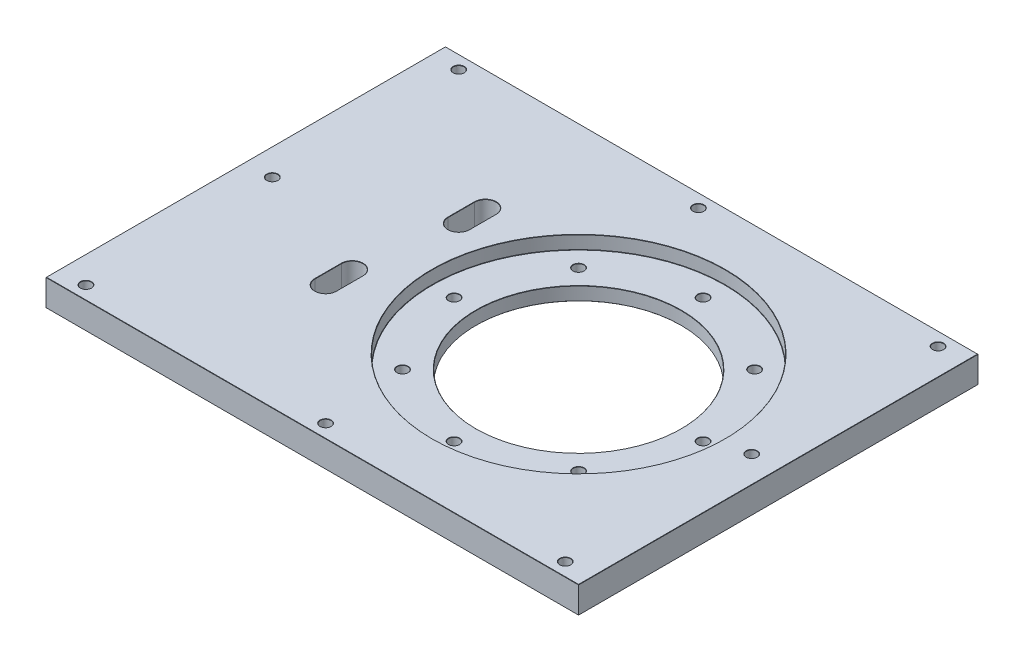
from build123d import *

# Parameters (mm, degrees)
SKETCH1_W           = 200
SKETCH1_H           = 150
SKETCH1_R           = 2
SKETCH1_R_2         = 55
BOSS_EXTRUDE1_DEPTH = 10
SKETCH1_3_R         = 55
SKETCH1_3_R_2       = 38.5
BOSS_EXTRUDE2_DEPTH = 5
SKETCH1_4_R         = 38.5
BOSS_EXTRUDE3_DEPTH = 9
SKETCH2_R           = 2
CUT_EXTRUDE1_DEPTH  = 146.859521458
SKETCH1_5_R         = 38.5
CUT_EXTRUDE2_DEPTH  = 147.116391962
CUT_EXTRUDE3_DEPTH  = 147.116391962
CHAMFER1_SIZE       = 0.1


with BuildPart() as part:
    # Sketch1 → Boss-Extrude1 (new body)
    with BuildSketch(Plane(origin=(0, 0, 0), x_dir=(1, 0, 0), z_dir=(0, 1, 0))):
        with Locations((-25, 0)):
            Rectangle(SKETCH1_W, SKETCH1_H)
        with Locations((-115, -70)):
            Circle(SKETCH1_R, mode=Mode.SUBTRACT)
        with Locations((-25, -70)):
            Circle(SKETCH1_R, mode=Mode.SUBTRACT)
        with Locations((65, -70)):
            Circle(SKETCH1_R, mode=Mode.SUBTRACT)
        with Locations((-115, 0)):
            Circle(SKETCH1_R, mode=Mode.SUBTRACT)
        with Locations((-115, 70)):
            Circle(SKETCH1_R, mode=Mode.SUBTRACT)
        Circle(SKETCH1_R_2, mode=Mode.SUBTRACT)
        with Locations((65, 0)):
            Circle(SKETCH1_R, mode=Mode.SUBTRACT)
        with Locations((-25, 70)):
            Circle(SKETCH1_R, mode=Mode.SUBTRACT)
        with Locations((65, 70)):
            Circle(SKETCH1_R, mode=Mode.SUBTRACT)
    extrude(amount=BOSS_EXTRUDE1_DEPTH)

    # Sketch1_3 → Boss-Extrude2 (add)
    with BuildSketch(Plane(origin=(0, 0, 0), x_dir=(1, 0, 0), z_dir=(0, 1, 0))):
        Circle(SKETCH1_3_R)
        Circle(SKETCH1_3_R_2, mode=Mode.SUBTRACT)
    extrude(amount=BOSS_EXTRUDE2_DEPTH)

    # Sketch1_4 → Boss-Extrude3 (add)
    with BuildSketch(Plane(origin=(0, 0, 0), x_dir=(1, 0, 0), z_dir=(0, 1, 0))):
        Circle(SKETCH1_4_R)
    extrude(amount=BOSS_EXTRUDE3_DEPTH)

    # Sketch2 → Cut-Extrude1 (cut, through all)
    with BuildSketch(Plane(origin=(0, 5, 0), x_dir=(1, 0, 0), z_dir=(0, 1, 0))):
        with Locations((0, 46.75)):
            Circle(SKETCH2_R)
        with Locations((33.05724202, 33.05724202)):
            Circle(SKETCH2_R)
        with Locations((46.75, 0)):
            Circle(SKETCH2_R)
        with Locations((33.05724202, -33.05724202)):
            Circle(SKETCH2_R)
        with Locations((0, -46.75)):
            Circle(SKETCH2_R)
        with Locations((-33.05724202, -33.05724202)):
            Circle(SKETCH2_R)
        with Locations((-46.75, 0)):
            Circle(SKETCH2_R)
        with Locations((-33.05724202, 33.05724202)):
            Circle(SKETCH2_R)
    extrude(amount=-CUT_EXTRUDE1_DEPTH, mode=Mode.SUBTRACT)

    # Sketch1_5 → Cut-Extrude2 (cut, through all)
    with BuildSketch(Plane(origin=(0, 0, 0), x_dir=(1, 0, 0), z_dir=(0, 1, 0))):
        Circle(SKETCH1_5_R)
    extrude(amount=CUT_EXTRUDE2_DEPTH, mode=Mode.SUBTRACT)

    # Sketch4 → Cut-Extrude3 (cut, through all)
    with BuildSketch(Plane(origin=(0, 10, 0), x_dir=(1, 0, 0), z_dir=(0, 1, 0))):
        with BuildLine():
            Line((-61, 30), (-61, 20))
            ThreePointArc((-61, 20), (-65, 16), (-69, 20))
            Line((-69, 20), (-69, 30))
            ThreePointArc((-69, 30), (-65, 34), (-61, 30))
        make_face()
        with BuildLine():
            Line((-74, -25), (-74, -15))
            ThreePointArc((-74, -15), (-70, -11), (-66, -15))
            Line((-66, -15), (-66, -25))
            ThreePointArc((-66, -25), (-70, -29), (-74, -25))
        make_face()
    extrude(amount=-CUT_EXTRUDE3_DEPTH, mode=Mode.SUBTRACT)

    # Chamfer1
    chamfer1_edges = [part.edges().sort_by_distance(p)[0] for p in [
        (-117, 0, 70),
        (-25, 0, -75),
        (-125, 0, 0),
        (-25, 0, 75),
        (75, 0, 0),
        (63, 0, -70),
        (-117, 0, -70),
        (63, 0, 70),
        (-35.05724202, 0, -33.05724202),
        (-48.75, 0, 0),
        (-35.05724202, 0, 33.05724202),
        (-2, 0, 46.75),
        (31.05724202, 0, 33.05724202),
        (44.75, 0, 0),
        (31.05724202, 0, -33.05724202),
        (-2, 0, -46.75),
        (-38.5, 0, 0),
        (-117, 10, 70),
        (-25, 10, 75),
        (-125, 10, 0),
        (-25, 10, -75),
        (75, 10, 0),
        (-55, 10, 0),
        (63, 10, -70),
        (-117, 10, -70),
        (63, 10, 70),
        (-55, 5, 0),
        (-38.5, 5, 0),
        (-35.05724202, 5, -33.05724202),
        (-48.75, 5, 0),
        (-35.05724202, 5, 33.05724202),
        (-2, 5, 46.75),
        (31.05724202, 5, 33.05724202),
        (44.75, 5, 0),
        (31.05724202, 5, -33.05724202),
        (-2, 5, -46.75),
        (-70, 0, 11),
        (-66, 0, 20),
        (-70, 0, 29),
        (-74, 0, 20),
        (-65, 0, -16),
        (-69, 0, -25),
        (-65, 0, -34),
        (-61, 0, -25),
        (-66, 10, 20),
        (-70, 10, 11),
        (-74, 10, 20),
        (-70, 10, 29),
        (-69, 10, -25),
        (-65, 10, -16),
        (-61, 10, -25),
        (-65, 10, -34),
        (-27, 0, 70),
        (-27, 0, -70),
        (-27, 10, 70),
        (-27, 10, -70),
        (63, 0, 0),
        (-117, 0, 0),
        (63, 10, 0),
        (-117, 10, 0),
    ]]
    chamfer(chamfer1_edges, length=CHAMFER1_SIZE)


solid = part.part
